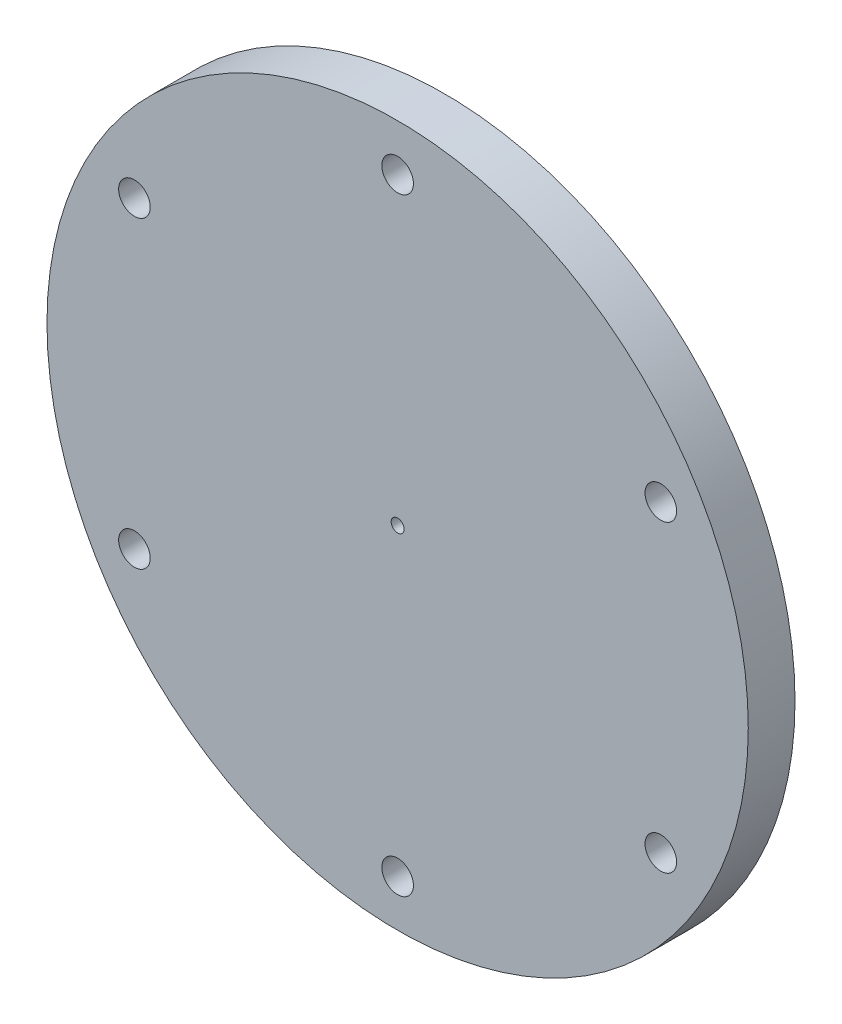
from build123d import *

# Parameters (mm, degrees)
SKETCH1_R           = 37.5
BOSS_EXTRUDE1_DEPTH = 5
SKETCH2_R           = 0.693
CUT_EXTRUDE1_DEPTH  = 6
SKETCH3_R           = 1.69
CUT_EXTRUDE2_DEPTH  = 6


with BuildPart() as part:
    # Sketch1 → Boss-Extrude1 (new body)
    with BuildSketch(Plane.XY):
        Circle(SKETCH1_R)
    extrude(amount=BOSS_EXTRUDE1_DEPTH)

    # Sketch2 → Cut-Extrude1 (cut, through all)
    with BuildSketch(Plane(origin=(0, 0, 0), x_dir=(-1, 0, 0), z_dir=(0, 0, -1))):
        Circle(SKETCH2_R)
    extrude(amount=-CUT_EXTRUDE1_DEPTH, mode=Mode.SUBTRACT)

    # Sketch3 → Cut-Extrude2 (cut, through all)
    with BuildSketch(Plane(origin=(0, 0, 0), x_dir=(-1, 0, 0), z_dir=(0, 0, -1))):
        with Locations((0, 32.5)):
            Circle(SKETCH3_R)
        with Locations((28.145825623, 16.25)):
            Circle(SKETCH3_R)
        with Locations((28.145825623, -16.25)):
            Circle(SKETCH3_R)
        with Locations((0, -32.5)):
            Circle(SKETCH3_R)
        with Locations((-28.145825623, -16.25)):
            Circle(SKETCH3_R)
        with Locations((-28.145825623, 16.25)):
            Circle(SKETCH3_R)
    extrude(amount=-CUT_EXTRUDE2_DEPTH, mode=Mode.SUBTRACT)


solid = part.part
